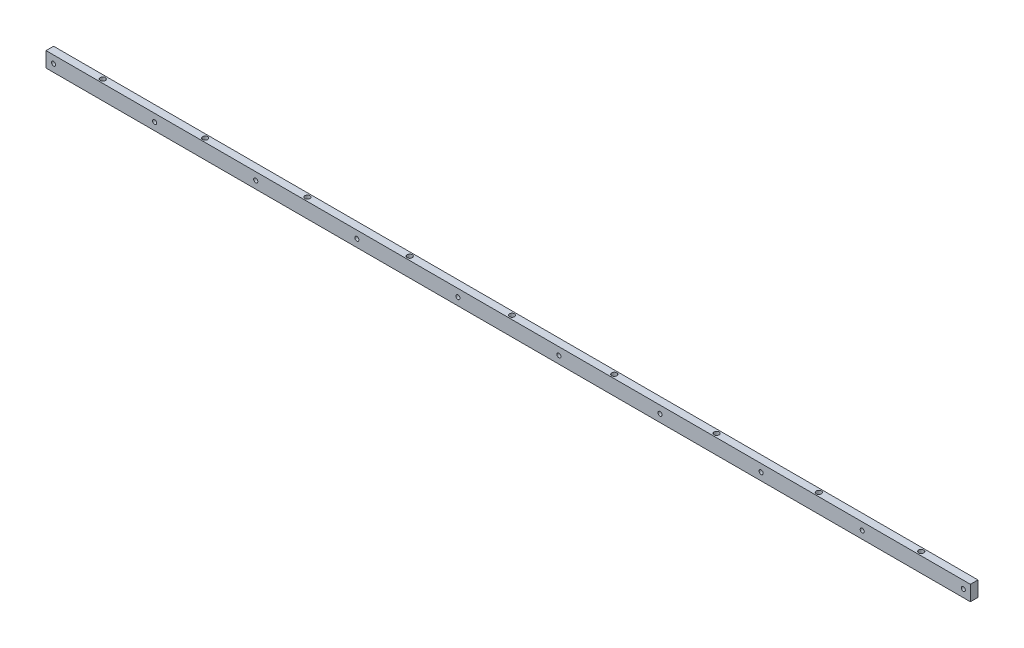
from build123d import *

# Parameters (mm, degrees)
SKETCH1_W           = 1549.4
SKETCH1_H           = 25.4
SKETCH1_R           = 3.429
BOSS_EXTRUDE1_DEPTH = 12.7
HOLE1_D             = 5.588
HOLE1_CBORE_D       = 8.636
HOLE1_CBORE_DEPTH   = 10.922
LPATTERN1_COUNT     = 9
LPATTERN1_PITCH     = 171.45
LPATTERN2_COUNT     = 9
LPATTERN2_PITCH     = 171.45


with BuildPart() as part:
    # Sketch1 → Boss-Extrude1 (new body)
    with BuildSketch(Plane.XY):
        with Locations((774.7, 12.7)):
            Rectangle(SKETCH1_W, SKETCH1_H)
        with Locations((12.7, 12.7)):
            Circle(SKETCH1_R, mode=Mode.SUBTRACT)
        with Locations((182.118, 12.7)):
            Circle(SKETCH1_R, mode=Mode.SUBTRACT)
        with Locations((351.536, 12.7)):
            Circle(SKETCH1_R, mode=Mode.SUBTRACT)
        with Locations((520.954, 12.7)):
            Circle(SKETCH1_R, mode=Mode.SUBTRACT)
        with Locations((690.372, 12.7)):
            Circle(SKETCH1_R, mode=Mode.SUBTRACT)
        with Locations((859.79, 12.7)):
            Circle(SKETCH1_R, mode=Mode.SUBTRACT)
        with Locations((1029.208, 12.7)):
            Circle(SKETCH1_R, mode=Mode.SUBTRACT)
        with Locations((1198.626, 12.7)):
            Circle(SKETCH1_R, mode=Mode.SUBTRACT)
        with Locations((1368.044, 12.7)):
            Circle(SKETCH1_R, mode=Mode.SUBTRACT)
        with Locations((1537.462, 12.7)):
            Circle(SKETCH1_R, mode=Mode.SUBTRACT)
    extrude(amount=-BOSS_EXTRUDE1_DEPTH)

    # Hole1 (through all)
    with Locations(Plane(origin=(88.9, 25.4, -6.35), x_dir=(0, 0, 1), z_dir=(0, 1, 0))):
        with Locations((0, 0)):
            hole1 = CounterBoreHole(HOLE1_D / 2, HOLE1_CBORE_D / 2, HOLE1_CBORE_DEPTH)

    # LPattern1: Hole1 ×9
    with Locations(*[(i * LPATTERN1_PITCH, 0, 0) for i in range(1, LPATTERN1_COUNT)]):
        add(hole1, mode=Mode.SUBTRACT)

    # Sketch5 → Hole2 (revolve, cut)
    with BuildSketch(Plane(origin=(88.9, 0, -6.35), x_dir=(0, 0, -1), z_dir=(1, 0, 0))):
        Polygon((0, 0), (0, 25.4), (2.794, 25.4), (2.794, 9.906), (2.54, 9.906), (2.54, 0), align=None)
    hole2 = revolve(axis=Axis((88.9, 110, -6.35), (0, -1, 0)), mode=Mode.SUBTRACT)

    # LPattern2: Hole2 ×9
    with Locations(*[(i * LPATTERN2_PITCH, 0, 0) for i in range(1, LPATTERN2_COUNT)]):
        add(hole2, mode=Mode.SUBTRACT)


solid = part.part
